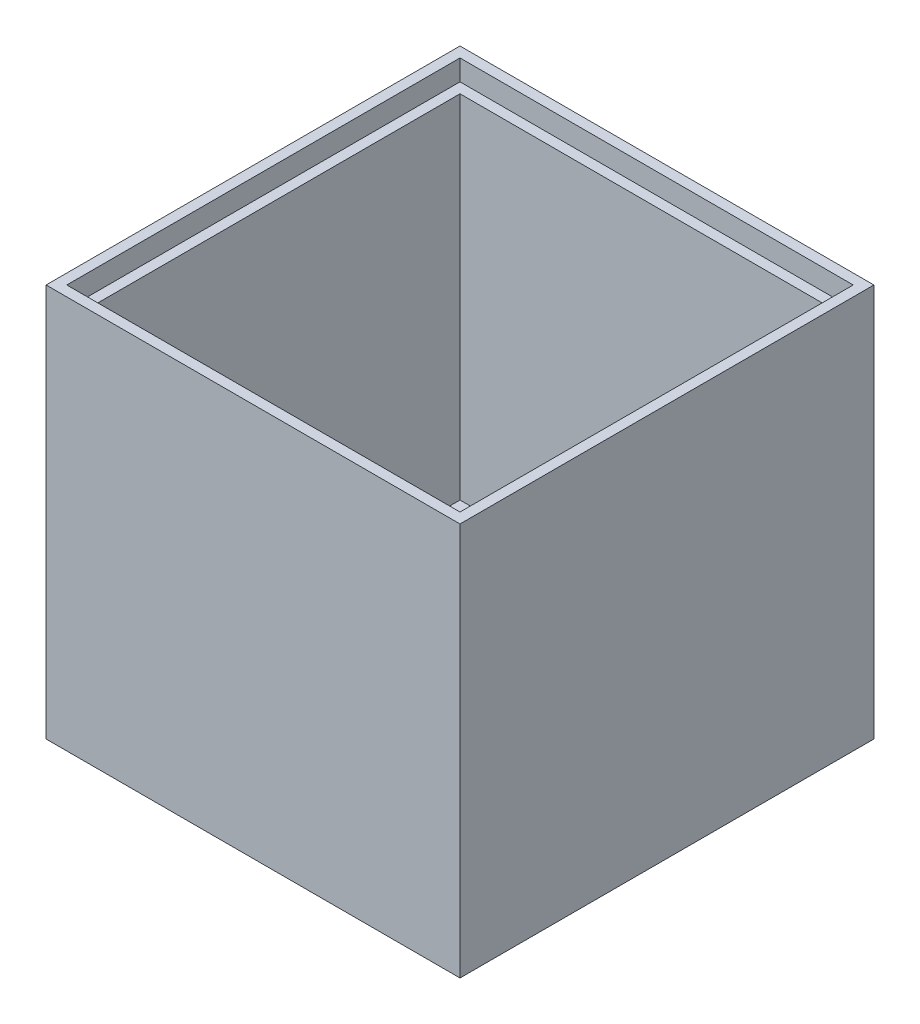
from build123d import *

# Parameters (mm, degrees)
SKETCH1_W           = 50.8
SKETCH1_H           = 50.8
BOSS_EXTRUDE1_DEPTH = 48.26
SKETCH2_W           = 45.72
SKETCH2_H           = 45.72
CUT_EXTRUDE1_DEPTH  = 45.72
SKETCH3_W           = 48.26
SKETCH3_H           = 48.26
CUT_EXTRUDE2_DEPTH  = 2.54


with BuildPart() as part:
    # Sketch1 → Boss-Extrude1 (new body)
    with BuildSketch(Plane(origin=(0, 0, 0), x_dir=(1, 0, 0), z_dir=(0, 1, 0))):
        with Locations((25.4, 25.4)):
            Rectangle(SKETCH1_W, SKETCH1_H)
    extrude(amount=BOSS_EXTRUDE1_DEPTH)

    # Sketch2 → Cut-Extrude1 (cut)
    with BuildSketch(Plane(origin=(0, 48.26, 0), x_dir=(1, 0, 0), z_dir=(0, 1, 0))):
        with Locations((25.4, 25.4)):
            Rectangle(SKETCH2_W, SKETCH2_H)
    extrude(amount=-CUT_EXTRUDE1_DEPTH, mode=Mode.SUBTRACT)

    # Sketch3 → Cut-Extrude2 (cut)
    with BuildSketch(Plane(origin=(0, 48.26, 0), x_dir=(1, 0, 0), z_dir=(0, 1, 0))):
        with Locations((25.4, 25.4)):
            Rectangle(SKETCH3_W, SKETCH3_H)
    extrude(amount=-CUT_EXTRUDE2_DEPTH, mode=Mode.SUBTRACT)


solid = part.part
